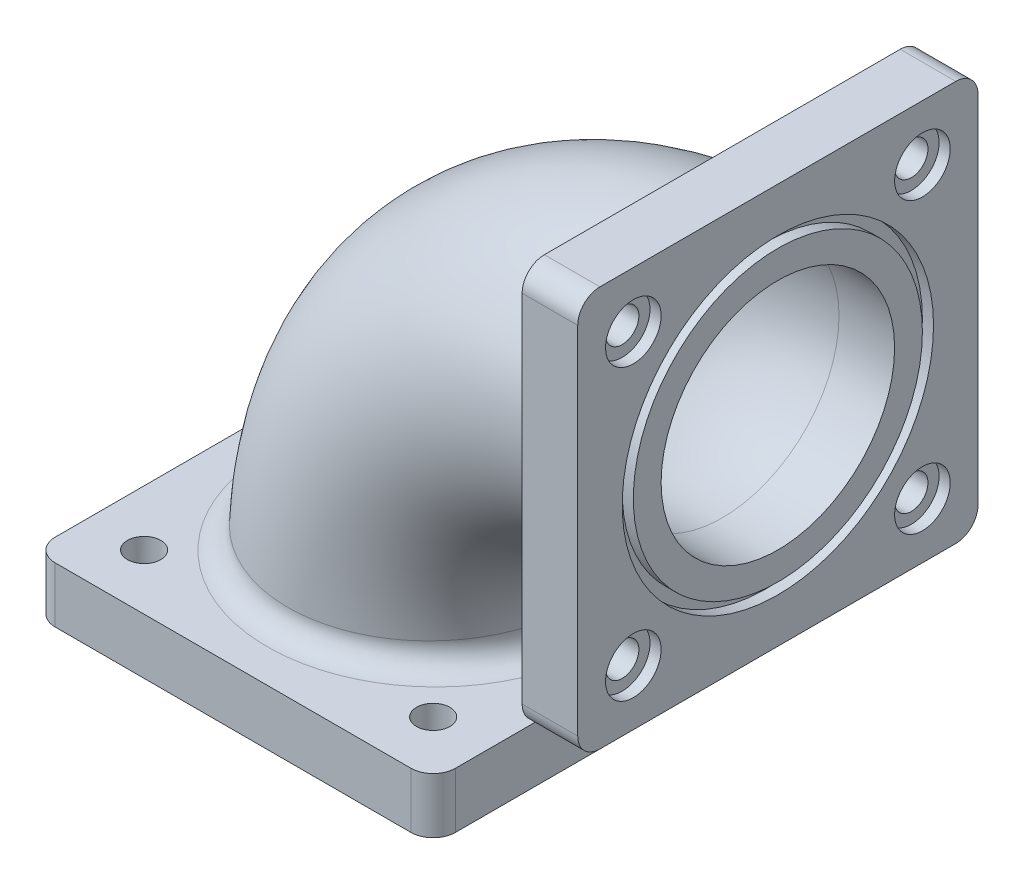
from build123d import *

# Parameters (mm, degrees)
SKETCH6_R                  = 13
SKETCH6_R_2                = 10.5
REVOLVE1_ANGLE             = 90
SKETCH6_2_R                = 13
SKETCH6_2_R_2              = 10.5
BOSS_EXTRUDE1_DEPTH        = 5
SKETCH9_W                  = 36
SKETCH9_H                  = 36
BOSS_EXTRUDE2_DEPTH        = 5
SKETCH10_R                 = 10.5
CUT_EXTRUDE1_DEPTH         = 5
SKETCH11_R                 = 14
SKETCH11_R_2               = 13
CUT_EXTRUDE2_DEPTH         = 1
HOLE1_D                    = 3
HOLE1_DEPTH                = 5
HOLE1_CBORE_D              = 5
HOLE1_CBORE_DEPTH          = 1
LPATTERN1_COUNT            = 2
LPATTERN1_PITCH            = 26
LPATTERN1_COUNT_DIR2       = 2
LPATTERN1_PITCH_DIR2       = 26
FILLET1_R                  = 2
MIRROR1_COPY_1_D           = 3
MIRROR1_COPY_1_DEPTH       = 5
MIRROR1_COPY_1_CBORE_D     = 5
MIRROR1_COPY_1_CBORE_DEPTH = 1
MIRROR1_COPY_2_D           = 3
MIRROR1_COPY_2_DEPTH       = 5
MIRROR1_COPY_2_CBORE_D     = 5
MIRROR1_COPY_2_CBORE_DEPTH = 1
MIRROR1_COPY_3_D           = 3
MIRROR1_COPY_3_DEPTH       = 5
MIRROR1_COPY_3_CBORE_D     = 5
MIRROR1_COPY_3_CBORE_DEPTH = 1
FILLET1_OF_MIRROR1_R       = 2


with BuildPart() as part:
    # Sketch6 → Revolve1 (revolve)
    with BuildSketch(Plane(origin=(0, 0, 0), x_dir=(0, 0, -1), z_dir=(1, 0, 0))):
        with Locations((0, 26)):
            Circle(SKETCH6_R)
        with Locations((0, 26)):
            Circle(SKETCH6_R_2, mode=Mode.SUBTRACT)
    revolve(axis=Axis((0, 0, -14.3), (0, 0, 1)), revolution_arc=REVOLVE1_ANGLE)

    # Sketch6_2 → Boss-Extrude1 (add)
    with BuildSketch(Plane(origin=(0, 0, 0), x_dir=(0, 0, -1), z_dir=(1, 0, 0))):
        with Locations(Location((0, 26, 0), (0, 0, 90))):
            Circle(SKETCH6_2_R)
        with Locations(Location((0, 26, 0), (0, 0, 90))):
            Circle(SKETCH6_2_R_2, mode=Mode.SUBTRACT)
    boss_extrude1 = extrude(amount=BOSS_EXTRUDE1_DEPTH)

    # Sketch9 → Boss-Extrude2 (add)
    with BuildSketch(Plane(origin=(5, 0, 0), x_dir=(0, 0, -1), z_dir=(1, 0, 0))):
        with Locations((0, 26)):
            Rectangle(SKETCH9_W, SKETCH9_H)
    boss_extrude2 = extrude(amount=-BOSS_EXTRUDE2_DEPTH)

    # Sketch10 → Cut-Extrude1 (cut)
    with BuildSketch(Plane(origin=(5, 0, 0), x_dir=(0, 0, -1), z_dir=(1, 0, 0))):
        with Locations((0, 26)):
            Circle(SKETCH10_R)
    cut_extrude1 = extrude(amount=-CUT_EXTRUDE1_DEPTH, mode=Mode.SUBTRACT)

    # Sketch11 → Cut-Extrude2 (cut)
    with BuildSketch(Plane(origin=(5, 0, 0), x_dir=(0, 0, -1), z_dir=(1, 0, 0))):
        with Locations((0, 26)):
            Circle(SKETCH11_R)
        with Locations((0, 26)):
            Circle(SKETCH11_R_2, mode=Mode.SUBTRACT)
    cut_extrude2 = extrude(amount=-CUT_EXTRUDE2_DEPTH, mode=Mode.SUBTRACT)

    # Hole1
    with Locations(Plane(origin=(5, 39, 13), x_dir=(0, 0, 1), z_dir=(1, 0, 0))):
        with Locations((0, 0)):
            hole1 = CounterBoreHole(HOLE1_D / 2, HOLE1_CBORE_D / 2, HOLE1_CBORE_DEPTH, depth=HOLE1_DEPTH)

    # LPattern1: Hole1 2 × 2
    with Locations(*[(0, -j * LPATTERN1_PITCH_DIR2, -i * LPATTERN1_PITCH) for i in range(LPATTERN1_COUNT) for j in range(LPATTERN1_COUNT_DIR2) if (i, j) != (0, 0)]):
        add(hole1, mode=Mode.SUBTRACT)

    # Fillet1
    fillet1_edges = [part.edges().sort_by_distance(p)[0] for p in [
        (2.5, 44, -18),
        (2.5, 8, -18),
        (2.5, 8, 18),
        (2.5, 44, 18),
        (0, 26, 13),
    ]]
    fillet(fillet1_edges, radius=FILLET1_R)

    # Mirror1: Boss-Extrude1, Boss-Extrude2, Cut-Extrude1, Cut-Extrude2, Hole1 across plane
    add(boss_extrude1.mirror(Plane(origin=(0, 0, 0), x_dir=(0, 0, 1), z_dir=(0.7071067811865475, 0.7071067811865477, 0))))
    add(boss_extrude2.mirror(Plane(origin=(0, 0, 0), x_dir=(0, 0, 1), z_dir=(0.7071067811865475, 0.7071067811865477, 0))))
    add(cut_extrude1.mirror(Plane(origin=(0, 0, 0), x_dir=(0, 0, 1), z_dir=(0.7071067811865475, 0.7071067811865477, 0))), mode=Mode.SUBTRACT)
    add(cut_extrude2.mirror(Plane(origin=(0, 0, 0), x_dir=(0, 0, 1), z_dir=(0.7071067811865475, 0.7071067811865477, 0))), mode=Mode.SUBTRACT)
    add(hole1.mirror(Plane(origin=(0, 0, 0), x_dir=(0, 0, 1), z_dir=(0.7071067811865475, 0.7071067811865477, 0))), mode=Mode.SUBTRACT)

    # Mirror1 copy 1
    with Locations(Plane(origin=(-13, -5, 13), x_dir=(0, 0, 1), z_dir=(0, -1, 0))):
        with Locations((0, 0)):
            CounterBoreHole(MIRROR1_COPY_1_D / 2, MIRROR1_COPY_1_CBORE_D / 2, MIRROR1_COPY_1_CBORE_DEPTH, depth=MIRROR1_COPY_1_DEPTH)

    # Mirror1 copy 2
    with Locations(Plane(origin=(-39, -5, -13), x_dir=(0, 0, 1), z_dir=(0, -1, 0))):
        with Locations((0, 0)):
            CounterBoreHole(MIRROR1_COPY_2_D / 2, MIRROR1_COPY_2_CBORE_D / 2, MIRROR1_COPY_2_CBORE_DEPTH, depth=MIRROR1_COPY_2_DEPTH)

    # Mirror1 copy 3
    with Locations(Plane(origin=(-13, -5, -13), x_dir=(0, 0, 1), z_dir=(0, -1, 0))):
        with Locations((0, 0)):
            CounterBoreHole(MIRROR1_COPY_3_D / 2, MIRROR1_COPY_3_CBORE_D / 2, MIRROR1_COPY_3_CBORE_DEPTH, depth=MIRROR1_COPY_3_DEPTH)

    # Fillet1 of Mirror1
    fillet1_of_mirror1_edges = [part.edges().sort_by_distance(p)[0] for p in [
        (-44, -2.5, -18),
        (-8, -2.5, -18),
        (-8, -2.5, 18),
        (-44, -2.5, 18),
        (-26, 0, 13),
    ]]
    fillet(fillet1_of_mirror1_edges, radius=FILLET1_OF_MIRROR1_R)


solid = part.part
